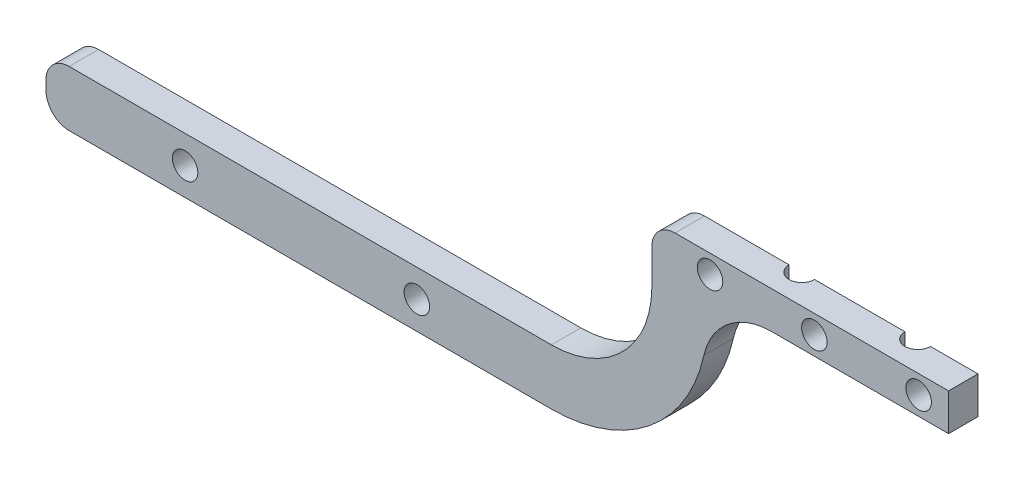
from build123d import *

# Parameters (mm, degrees)
BOSS_EXTRUDE1_DEPTH = 6.35
FILLET1_R           = 5
FILLET2_R           = 15
SKETCH4_R           = 2.75
CUT_EXTRUDE2_DEPTH  = 10
CUT_EXTRUDE3_REACH  = 48.24
SKETCH3_R           = 2.75


with BuildPart() as part:
    # Sketch1 → Boss-Extrude1 (new body)
    with BuildSketch(Plane.XY):
        with BuildLine():
            Line((0, 0), (-64, 0))
            Line((-64, 0), (-64, -12.552169744))
            ThreePointArc((-64, -12.552169744), (-70.352218413, -27.887781587), (-85.687830256, -34.24))
            Line((-85.687830256, -34.24), (-194.687830256, -34.24))
            Line((-194.687830256, -34.24), (-194.687830256, -46.24))
            Line((-194.687830256, -46.24), (-85.687830256, -46.24))
            ThreePointArc((-85.687830256, -46.24), (-61.866937038, -36.373062962), (-52, -12.552169744))
            Line((-52, -12.552169744), (-52, -8))
            Line((-52, -8), (0, -8))
            Line((0, -8), (0, 0))
        make_face()
    extrude(amount=BOSS_EXTRUDE1_DEPTH)

    # Fillet1
    fillet1_edges = [part.edges().sort_by_distance(p)[0] for p in [
        (-194.687830256, -46.24, 3.175),
        (-194.687830256, -34.24, 3.175),
        (-64, 0, 3.175),
    ]]
    fillet(fillet1_edges, radius=FILLET1_R)

    # Fillet2
    fillet2_edges = [part.edges().sort_by_distance(p)[0] for p in [
        (-52, -8, 3.175),
    ]]
    fillet(fillet2_edges, radius=FILLET2_R)

    # Sketch4 → Cut-Extrude2 (cut)
    with BuildSketch(Plane.XY.offset(6.35)):
        with Locations((-164.687830256, -40.24)):
            Circle(SKETCH4_R)
        with Locations((-114.687830256, -40.24)):
            Circle(SKETCH4_R)
        with Locations((-6.452530622, -4)):
            Circle(SKETCH4_R)
        with Locations((-28.952530622, -4)):
            Circle(SKETCH4_R)
        with Locations((-51.452530622, -4)):
            Circle(SKETCH4_R)
    extrude(amount=-CUT_EXTRUDE2_DEPTH, mode=Mode.SUBTRACT)

    # Sketch3 → Cut-Extrude3 (cut, up to next)
    with BuildSketch(Plane(origin=(0, 0, 0), x_dir=(1, 0, 0), z_dir=(0, 1, 0)), mode=Mode.PRIVATE) as cut_extrude3_sk1:
        with Locations((-13, 0)):
            Circle(SKETCH3_R)
    cut_extrude3_tool1 = extrude(cut_extrude3_sk1.sketch, amount=-CUT_EXTRUDE3_REACH, mode=Mode.PRIVATE) & part.part
    add(cut_extrude3_tool1.solids().sort_by_distance((-13, 0, 0))[0], mode=Mode.SUBTRACT)
    # Sketch3 → Cut-Extrude3 (cut, up to next)
    with BuildSketch(Plane(origin=(0, 0, 0), x_dir=(1, 0, 0), z_dir=(0, 1, 0)), mode=Mode.PRIVATE) as cut_extrude3_sk2:
        with Locations((-38, 0)):
            Circle(SKETCH3_R)
    cut_extrude3_tool2 = extrude(cut_extrude3_sk2.sketch, amount=-CUT_EXTRUDE3_REACH, mode=Mode.PRIVATE) & part.part
    add(cut_extrude3_tool2.solids().sort_by_distance((-38, 0, 0))[0], mode=Mode.SUBTRACT)


solid = part.part
